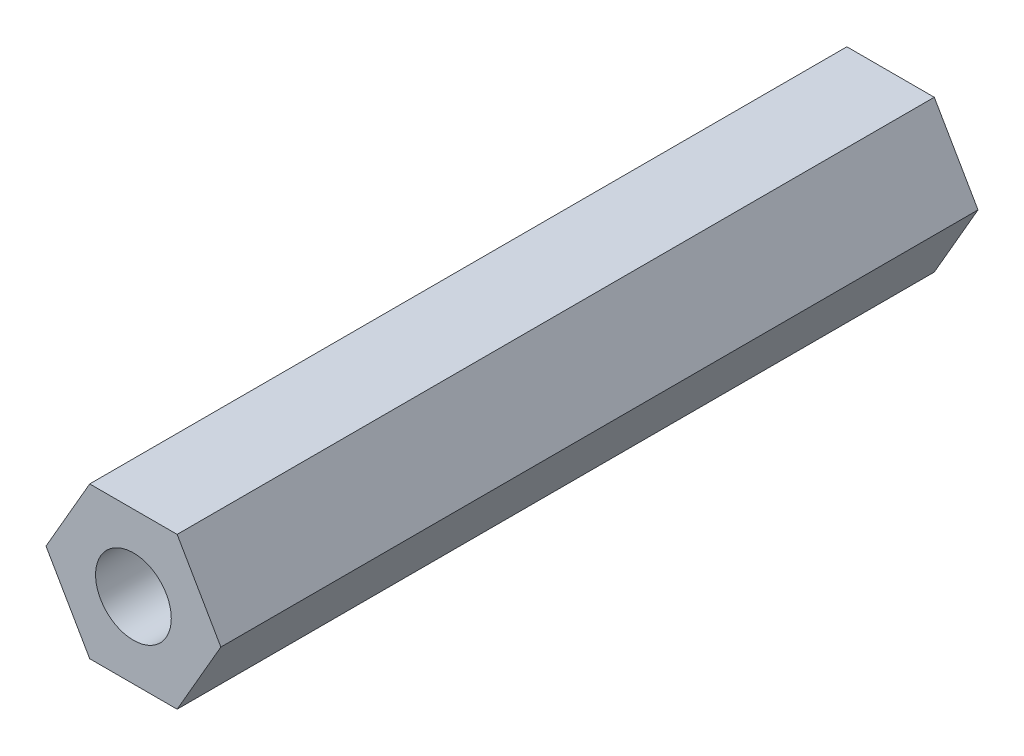
from build123d import *

# Parameters (mm, degrees)
EXTRUDE_1_DEPTH    = 25
HOLE_WIZARD_M3_1_D = 2.5


with BuildPart() as part:
    # 草图1 → 凸台-拉伸1 (new body)
    with BuildSketch(Plane.XY):
        Polygon((1.443375673, 2.5), (-1.443375673, 2.5), (-2.886751346, 0), (-1.443375673, -2.5), (1.443375673, -2.5), (2.886751346, 0), align=None)
    extrude(amount=EXTRUDE_1_DEPTH)

    # M3 螺纹孔1 (through all)
    with Locations(Plane.XY.offset(25)):
        with Locations((0, 0)):
            Hole(HOLE_WIZARD_M3_1_D / 2)


solid = part.part
